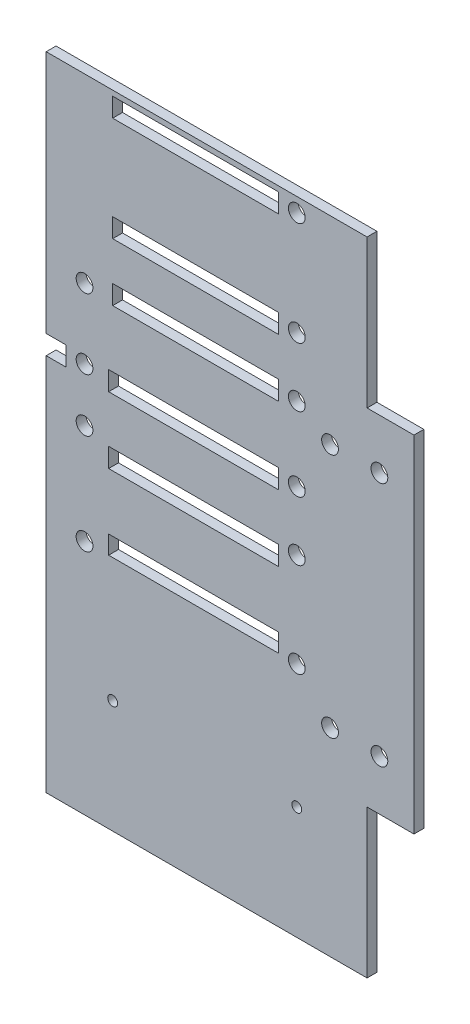
from build123d import *

# Parameters (mm, degrees)
ESQUISSE1_W             = 19
ESQUISSE1_H             = 70
ESQUISSE1_R             = 1.7
BOSS_EXTRU_1_DEPTH      = 2
BOSS_EXTRU_2_DEPTH      = 2
ESQUISSE3_R             = 1.7
ESQUISSE3_R_2           = 1
ESQUISSE3_W             = 34.416616224
ESQUISSE3_H             = 3.721706088
ESQUISSE3_H_2           = 3.894041755
ESQUISSE3_H_3           = 3.892627661
ESQUISSE3_W_2           = 33.600664609
ESQUISSE3_H_4           = 3.878874163
ESQUISSE3_H_5           = 3.860536167
ESQUISSE3_H_6           = 3.860536168
ESQUISSE3_W_3           = 4.02824374
ENL_V_MAT_EXTRU_1_DEPTH = 2
ESQUISSE4_R             = 1.7
ENL_V_MAT_EXTRU_2_DEPTH = 2


with BuildPart() as part:
    # Esquisse1 → Boss.-Extru.1 (new body)
    with BuildSketch(Plane.XY):
        with Locations((-2.5, -24.85)):
            Rectangle(ESQUISSE1_W, ESQUISSE1_H)
        Circle(ESQUISSE1_R, mode=Mode.SUBTRACT)
        with Locations((0, -49.7)):
            Circle(ESQUISSE1_R, mode=Mode.SUBTRACT)
    extrude(amount=BOSS_EXTRU_1_DEPTH)

    # Esquisse2 → Boss.-Extru.2 (add)
    with BuildSketch(Plane(origin=(0, 0, 0), x_dir=(-1, 0, 0), z_dir=(0, 0, -1))):
        Polygon((67.5, -22.717620887), (67.5, 40.15), (2.5, 40.15), (2.5, -89.85), (67.5, -89.85), (67.5, -26.982379113), align=None)
    extrude(amount=-BOSS_EXTRU_2_DEPTH)

    # Esquisse3 → Enlèv. mat.-Extru.1 (cut)
    with BuildSketch(Plane(origin=(0, 0, 0), x_dir=(-1, 0, 0), z_dir=(0, 0, -1))):
        with Locations((16.729252348, -41.85)):
            Circle(ESQUISSE3_R)
        with Locations((16.729252348, -66.968565228)):
            Circle(ESQUISSE3_R_2)
        with Locations((54.029252348, -66.968565228)):
            Circle(ESQUISSE3_R_2)
        with Locations((16.729252348, -22.75)):
            Circle(ESQUISSE3_R)
        with Locations((16.729252348, -10.75)):
            Circle(ESQUISSE3_R)
        with Locations((16.729252348, 4.25)):
            Circle(ESQUISSE3_R)
        with Locations((16.729252348, 16.25)):
            Circle(ESQUISSE3_R)
        with Locations((16.729252348, 37.25)):
            Circle(ESQUISSE3_R)
        with Locations((59.729252348, -41.85)):
            Circle(ESQUISSE3_R)
        with Locations((59.729252348, -21.55)):
            Circle(ESQUISSE3_R)
        with Locations((59.729252348, -10.75)):
            Circle(ESQUISSE3_R)
        with Locations((59.729252348, 3.45)):
            Circle(ESQUISSE3_R)
        with Locations((37.636895851, -39.989146956)):
            Rectangle(ESQUISSE3_W, ESQUISSE3_H)
        with Locations((37.636895851, -24.697020878)):
            Rectangle(ESQUISSE3_W, ESQUISSE3_H_2)
        with Locations((37.636895851, -11.228994179)):
            Rectangle(ESQUISSE3_W, ESQUISSE3_H_3)
        with Locations((37.228920043, 4.281571073)):
            Rectangle(ESQUISSE3_W_2, ESQUISSE3_H_4)
        with Locations((37.228920043, 16.012867078)):
            Rectangle(ESQUISSE3_W_2, ESQUISSE3_H_5)
        with Locations((37.228920043, 37.153497731)):
            Rectangle(ESQUISSE3_W_2, ESQUISSE3_H_6)
        with Locations((65.48587813, -11.228994179)):
            Rectangle(ESQUISSE3_W_3, ESQUISSE3_H_3)
    extrude(amount=-ENL_V_MAT_EXTRU_1_DEPTH, mode=Mode.SUBTRACT)

    # Esquisse4 → Enlèv. mat.-Extru.2 (cut)
    with BuildSketch(Plane(origin=(0, 0, 0), x_dir=(-1, 0, 0), z_dir=(0, 0, -1))):
        with Locations((10, -49.7)):
            Circle(ESQUISSE4_R)
        with Locations((10, 0)):
            Circle(ESQUISSE4_R)
    extrude(amount=-ENL_V_MAT_EXTRU_2_DEPTH, mode=Mode.SUBTRACT)


solid = part.part
